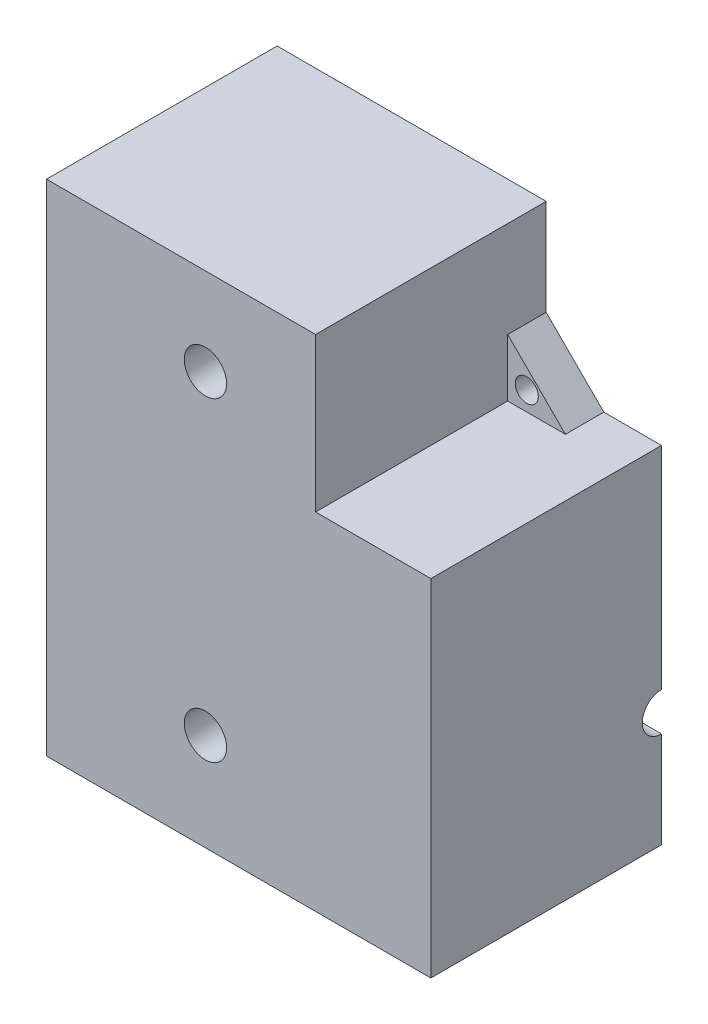
from build123d import *

# Parameters (mm, degrees)
BASE_EXTRUDE_DEPTH  = 5
SKETCH12_R          = 1.5
CUT_EXTRUDE11_DEPTH = 10
BOSS_EXTRUDE1_DEPTH = 25
CUT_EXTRUDE14_DEPTH = 20
CUT_EXTRUDE15_DEPTH = 20
SKETCH15_R          = 2.75
CUT_EXTRUDE16_DEPTH = 20
SKETCH16_R          = 2.5
EXTRUDE1_DEPTH      = 10
SKETCH17_R          = 2.75
EXTRUDE2_DEPTH      = 6


with BuildPart() as part:
    # Sketch1 → Base-Extrude (new body)
    with BuildSketch(Plane.XY):
        Polygon((-27.670446838, -25.657666931), (-27.670446838, -38.157666931), (-20.170446838, -45.657666931), (-12.670446838, -45.657666931), (-12.670446838, -90.657666931), (-32.670446838, -90.657666931), (-37.670446838, -96.707666931), (-42.670446838, -90.657666931), (-62.670446838, -90.657666931), (-62.670446838, -63.157666931), (-68.719237079, -58.157666931), (-62.670446838, -53.157666931), (-62.670446838, -25.657666931), align=None)
    extrude(amount=BASE_EXTRUDE_DEPTH)

    # Sketch12 → Cut-Extrude11 (cut)
    with BuildSketch(Plane.XY.offset(5)):
        with Locations((-65.219237079, -58.157666931)):
            Circle(SKETCH12_R)
        with Locations((-37.670446838, -93.207666931)):
            Circle(SKETCH12_R)
        with Locations((-25.195573104, -43.182793197)):
            Circle(SKETCH12_R)
    extrude(amount=-CUT_EXTRUDE11_DEPTH, mode=Mode.SUBTRACT)

    # Sketch13 → Boss-Extrude1 (add)
    with BuildSketch(Plane.XY.offset(5)):
        Polygon((-62.670446838, -25.657666931), (-62.670446838, -90.657666931), (-12.670446838, -90.657666931), (-12.670446838, -45.657666931), (-27.670446838, -45.657666931), (-27.670446838, -25.657666931), align=None)
    extrude(amount=BOSS_EXTRUDE1_DEPTH)

    # Sketch2 → Cut-Extrude14 (cut)
    with BuildSketch(Plane.XY.offset(5)):
        Polygon((-57.670446838, -55.511686018), (-57.670446838, -60.803647844), (-57.670446838, -85.657666931), (-40.31612782, -85.657666931), (-35.024765855, -85.657666931), (-17.670446838, -85.657666931), (-17.670446838, -50.657666931), (-22.24151465, -50.657666931), (-32.670446838, -50.657666931), (-32.670446838, -40.228734743), (-32.670446838, -30.657666931), (-57.670446838, -30.657666931), align=None)
    extrude(amount=-CUT_EXTRUDE14_DEPTH, mode=Mode.SUBTRACT)

    # Sketch14 → Cut-Extrude15 (cut)
    with BuildSketch(Plane(origin=(0, 0, 5), x_dir=(-1, 0, 0), z_dir=(0, 0, -1))):
        Polygon((32.670446838, -30.657666931), (57.670446838, -30.657666931), (57.670446838, -85.657666931), (17.670446838, -85.657666931), (17.670446838, -50.657666931), (32.670446838, -50.657666931), align=None)
    extrude(amount=-CUT_EXTRUDE15_DEPTH, mode=Mode.SUBTRACT)

    # Sketch15 → Cut-Extrude16 (cut)
    with BuildSketch(Plane.XY.offset(30)):
        with Locations((45, -75.657666931)):
            Circle(SKETCH15_R)
        with Locations((-42, -78)):
            Circle(SKETCH15_R)
    extrude(amount=-CUT_EXTRUDE16_DEPTH, mode=Mode.SUBTRACT)

    # Sketch16 → Extrude1 (cut)
    with BuildSketch(Plane(origin=(-12.670446838, 0, 0), x_dir=(0, 0, -1), z_dir=(1, 0, 0))):
        with Locations((0, -75.65766693)):
            Circle(SKETCH16_R)
    extrude(amount=-EXTRUDE1_DEPTH, mode=Mode.SUBTRACT)

    # Sketch17 → Extrude2 (cut)
    with BuildSketch(Plane(origin=(0, 0, 25), x_dir=(-1, 0, 0), z_dir=(0, 0, -1))):
        with Locations((42, -37)):
            Circle(SKETCH17_R)
    extrude(amount=-EXTRUDE2_DEPTH, mode=Mode.SUBTRACT)


solid = part.part
